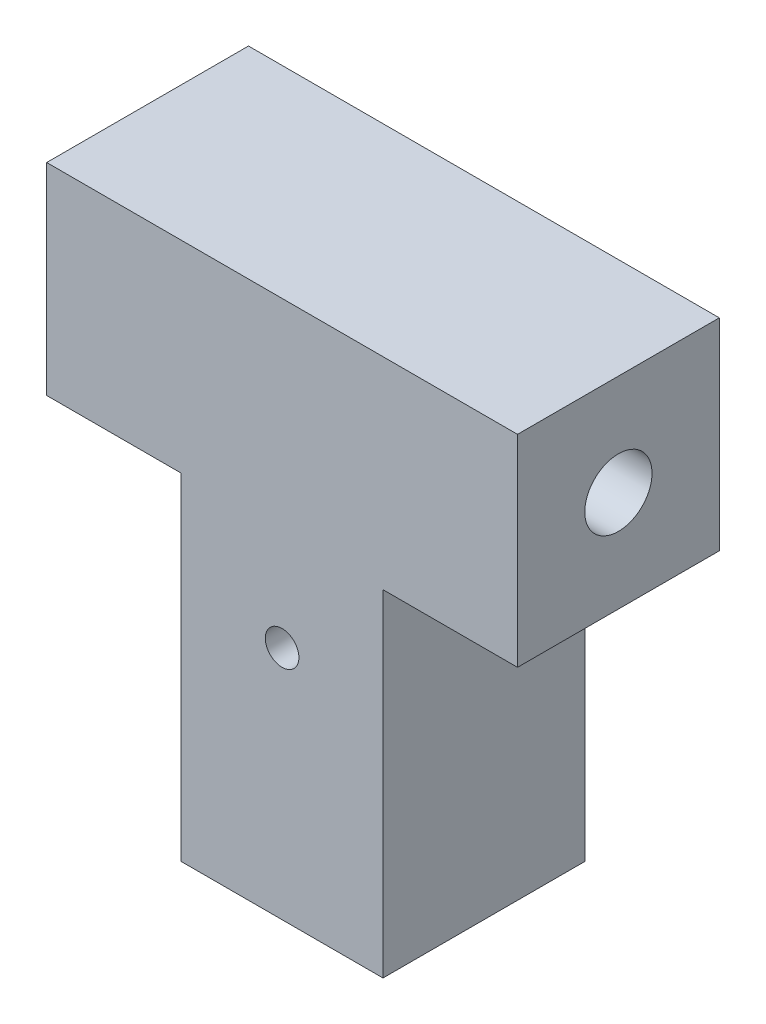
from build123d import *

# Parameters (mm, degrees)
SKETCH_1_W          = 12
SKETCH_1_H          = 12
EXTRUDE_1_DEPTH     = 20
SKETCH_2_W          = 28
SKETCH_2_H          = 12
EXTRUDE_2_DEPTH     = 12
SKETCH_3_R          = 2.5
CUT_EXTRUDE_1_DEPTH = 20
SKETCH_4_R          = 1
CUT_EXTRUDE_2_DEPTH = 13
SKETCH_5_R          = 2
CUT_EXTRUDE_3_DEPTH = 29


with BuildPart() as part:
    # Эскиз1 → Бобышка-Вытянуть1 (new body)
    with BuildSketch(Plane(origin=(0, 0, 0), x_dir=(1, 0, 0), z_dir=(0, 1, 0))):
        Rectangle(SKETCH_1_W, SKETCH_1_H)
    extrude(amount=EXTRUDE_1_DEPTH)

    # Эскиз2 → Бобышка-Вытянуть2 (add)
    with BuildSketch(Plane(origin=(0, 20, 0), x_dir=(1, 0, 0), z_dir=(0, 1, 0))):
        Rectangle(SKETCH_2_W, SKETCH_2_H)
    extrude(amount=EXTRUDE_2_DEPTH)

    # Эскиз3 → Вырез-Вытянуть1 (cut)
    with BuildSketch(Plane.XZ):
        Circle(SKETCH_3_R)
    extrude(amount=-CUT_EXTRUDE_1_DEPTH, mode=Mode.SUBTRACT)

    # Эскиз4 → Вырез-Вытянуть2 (cut, through all)
    with BuildSketch(Plane.XY.offset(6)):
        with Locations((0, 14)):
            Circle(SKETCH_4_R)
    extrude(amount=-CUT_EXTRUDE_2_DEPTH, mode=Mode.SUBTRACT)

    # Эскиз5 → Вырез-Вытянуть3 (cut, through all)
    with BuildSketch(Plane.ZY.offset(14)):
        with Locations((0, 26)):
            Circle(SKETCH_5_R)
    extrude(amount=-CUT_EXTRUDE_3_DEPTH, mode=Mode.SUBTRACT)


solid = part.part
